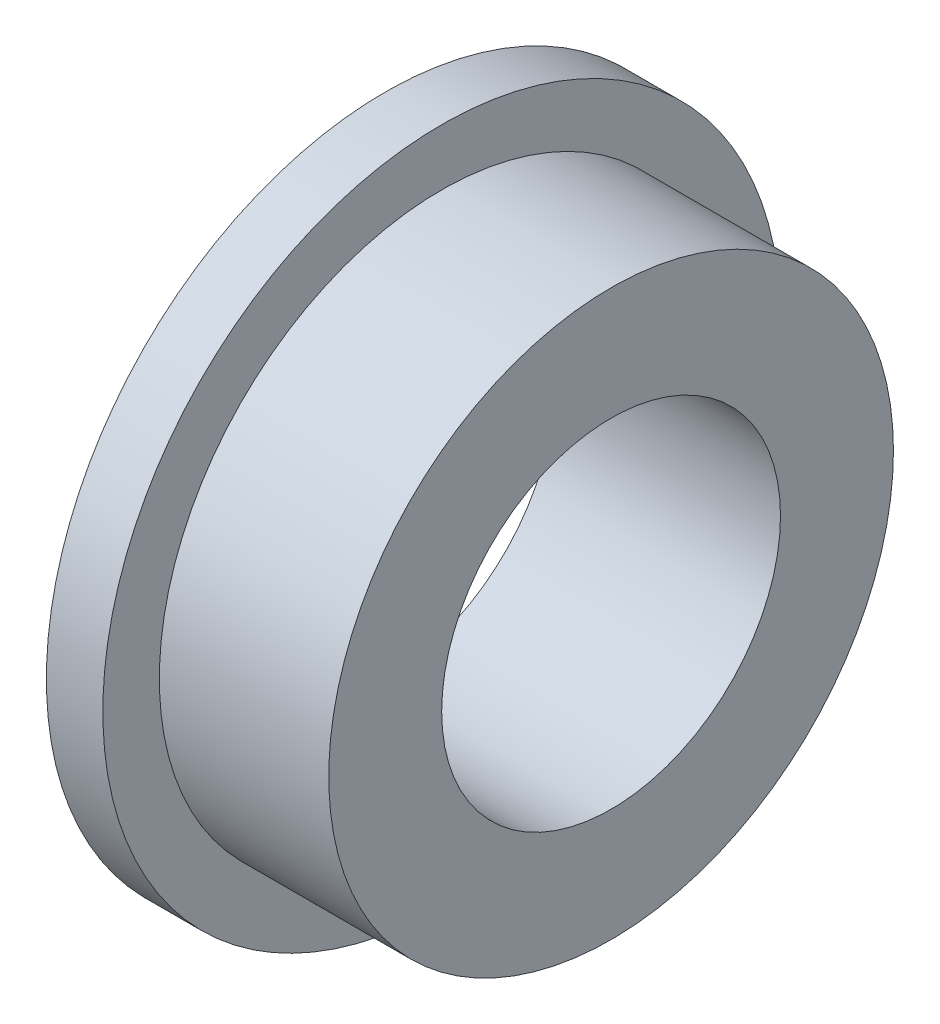
from build123d import *

# Parameters (mm, degrees)
SKETCH_1_R      = 6
SKETCH_1_R_2    = 3
EXTRUDE_1_DEPTH = 1
SKETCH_2_R      = 5
SKETCH_2_R_2    = 3
EXTRUDE_2_DEPTH = 3


with BuildPart() as part:
    # 草图1 → 凸台-拉伸1 (new body)
    with BuildSketch(Plane(origin=(0, 0, 0), x_dir=(0, 0, -1), z_dir=(1, 0, 0))):
        Circle(SKETCH_1_R)
        Circle(SKETCH_1_R_2, mode=Mode.SUBTRACT)
    extrude(amount=EXTRUDE_1_DEPTH)

    # 草图2 → 凸台-拉伸2 (add)
    with BuildSketch(Plane(origin=(1, 0, 0), x_dir=(0, 0, -1), z_dir=(1, 0, 0))):
        Circle(SKETCH_2_R)
        Circle(SKETCH_2_R_2, mode=Mode.SUBTRACT)
    extrude(amount=EXTRUDE_2_DEPTH)


solid = part.part
